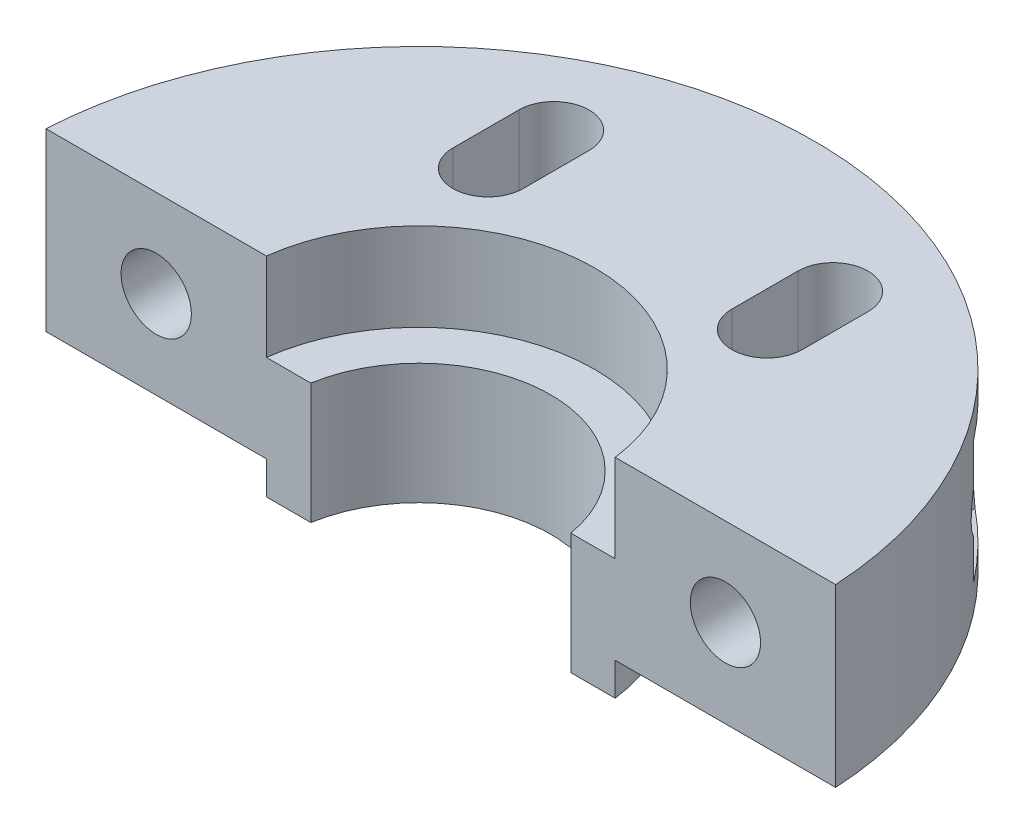
from build123d import *

# Parameters (mm, degrees)
SKETCH1_R           = 18
SKETCH1_R_2         = 8
BOSS_EXTRUDE1_DEPTH = 8
SKETCH2_R           = 8
SKETCH2_R_2         = 6
BOSS_EXTRUDE2_DEPTH = 5.5
SKETCH3_W           = 40
SKETCH3_H           = 20
CUT_EXTRUDE1_DEPTH  = 10.5
CUT_EXTRUDE2_REACH  = 19
SKETCH5_R           = 1.6
CUT_EXTRUDE3_REACH  = 29
CUT_EXTRUDE3_START  = -10


with BuildPart() as part:
    # Sketch1 → Boss-Extrude1 (new body)
    with BuildSketch(Plane(origin=(0, 0, 0), x_dir=(1, 0, 0), z_dir=(0, 1, 0))):
        Circle(SKETCH1_R)
        Circle(SKETCH1_R_2, mode=Mode.SUBTRACT)
        with BuildLine():
            Line((-7.950852961, 12.5), (-7.950852961, 9.5))
            ThreePointArc((-7.950852961, 9.5), (-6.350852961, 7.9), (-4.750852961, 9.5))
            Line((-4.750852961, 9.5), (-4.750852961, 12.5))
            ThreePointArc((-4.750852961, 12.5), (-6.350852961, 14.1), (-7.950852961, 12.5))
        make_face(mode=Mode.SUBTRACT)
        with BuildLine():
            Line((4.750852961, 12.5), (4.750852961, 9.5))
            ThreePointArc((4.750852961, 9.5), (6.350852961, 7.9), (7.950852961, 9.5))
            Line((7.950852961, 9.5), (7.950852961, 12.5))
            ThreePointArc((7.950852961, 12.5), (6.350852961, 14.1), (4.750852961, 12.5))
        make_face(mode=Mode.SUBTRACT)
    extrude(amount=BOSS_EXTRUDE1_DEPTH)

    # Sketch2 → Boss-Extrude2 (add)
    with BuildSketch(Plane(origin=(0, 4, 0), x_dir=(1, 0, 0), z_dir=(0, 1, 0))):
        Circle(SKETCH2_R)
        Circle(SKETCH2_R_2, mode=Mode.SUBTRACT)
    extrude(amount=-BOSS_EXTRUDE2_DEPTH)

    # Sketch3 → Cut-Extrude1 (cut, through all)
    with BuildSketch(Plane(origin=(0, 8, 0), x_dir=(1, 0, 0), z_dir=(0, 1, 0))):
        with Locations((0, -9)):
            Rectangle(SKETCH3_W, SKETCH3_H)
    extrude(amount=-CUT_EXTRUDE1_DEPTH, mode=Mode.SUBTRACT)

    # Sketch5 → Cut-Extrude2 (cut, up to next)
    with BuildSketch(Plane.XY.offset(-1), mode=Mode.PRIVATE) as cut_extrude2_sk1:
        with Locations((-12.954727344, 4)):
            Circle(SKETCH5_R)
    cut_extrude2_tool1 = extrude(cut_extrude2_sk1.sketch, amount=-CUT_EXTRUDE2_REACH, mode=Mode.PRIVATE) & part.part
    add(cut_extrude2_tool1.solids().sort_by_distance((-12.954727, 4, -1))[0], mode=Mode.SUBTRACT)
    # Sketch5 → Cut-Extrude2 (cut, up to next)
    with BuildSketch(Plane.XY.offset(-1), mode=Mode.PRIVATE) as cut_extrude2_sk2:
        with Locations((12.954727344, 4)):
            Circle(SKETCH5_R)
    cut_extrude2_tool2 = extrude(cut_extrude2_sk2.sketch, amount=-CUT_EXTRUDE2_REACH, mode=Mode.PRIVATE) & part.part
    add(cut_extrude2_tool2.solids().sort_by_distance((12.954727, 4, -1))[0], mode=Mode.SUBTRACT)

    # Sketch6 → Cut-Extrude3 (cut, up to next)
    with BuildSketch(Plane.XY.offset(-1).offset(CUT_EXTRUDE3_START), mode=Mode.PRIVATE) as cut_extrude3_sk1:
        Polygon((-9.721565837, 4), (-11.338146591, 6.8), (-14.571308098, 6.8), (-16.187888852, 4), (-14.571308098, 1.2), (-11.338146591, 1.2), align=None)
    cut_extrude3_tool1 = extrude(cut_extrude3_sk1.sketch, amount=-CUT_EXTRUDE3_REACH, mode=Mode.PRIVATE) & part.part
    add(cut_extrude3_tool1.solids().sort_by_distance((-12.954727, 4, -11))[0], mode=Mode.SUBTRACT)
    # Sketch6 → Cut-Extrude3 (cut, up to next)
    with BuildSketch(Plane.XY.offset(-1).offset(CUT_EXTRUDE3_START), mode=Mode.PRIVATE) as cut_extrude3_sk2:
        Polygon((16.187888852, 4), (14.571308098, 6.8), (11.338146591, 6.8), (9.721565837, 4), (11.338146591, 1.2), (14.571308098, 1.2), align=None)
    cut_extrude3_tool2 = extrude(cut_extrude3_sk2.sketch, amount=-CUT_EXTRUDE3_REACH, mode=Mode.PRIVATE) & part.part
    add(cut_extrude3_tool2.solids().sort_by_distance((12.954727, 4, -11))[0], mode=Mode.SUBTRACT)


solid = part.part
